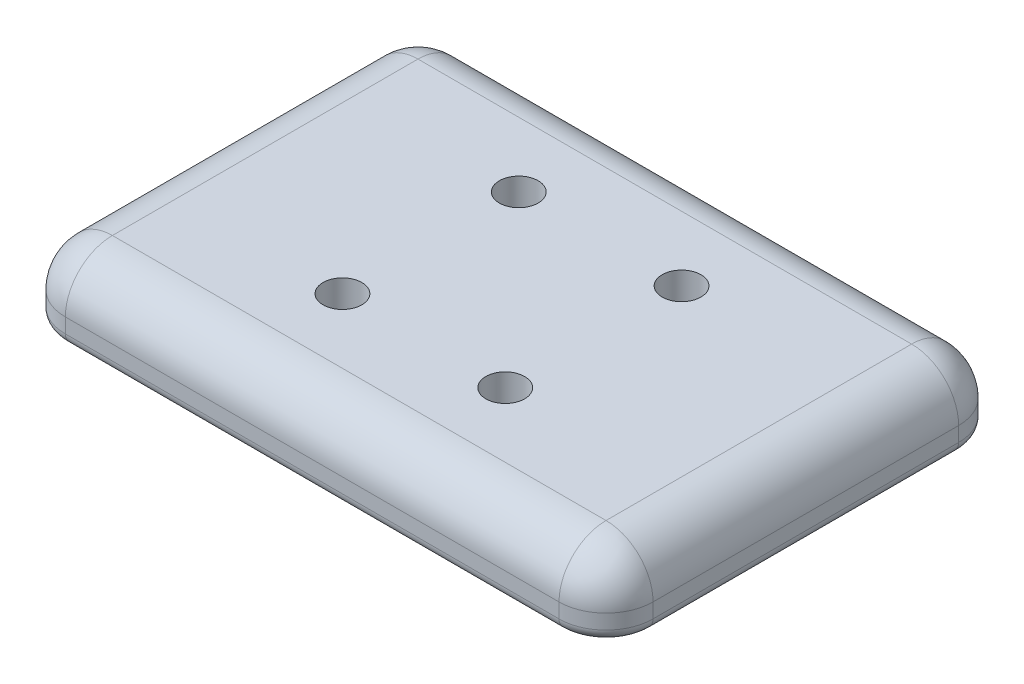
from build123d import *

# Parameters (mm, degrees)
SKETCH1_W                                    = 100
SKETCH1_H                                    = 68
BOSS_EXTRUDE1_DEPTH                          = 12.5
CBORE_FOR_M6_HEX_HEAD_CAP_SCREW1_D           = 6.6
CBORE_FOR_M6_HEX_HEAD_CAP_SCREW1_CBORE_D     = 14.547
CBORE_FOR_M6_HEX_HEAD_CAP_SCREW1_CBORE_DEPTH = 6
FILLET1_R                                    = 8
FILLET2_R                                    = 2


with BuildPart() as part:
    # Sketch1 → Boss-Extrude1 (new body)
    with BuildSketch(Plane(origin=(0, 0, 0), x_dir=(1, 0, 0), z_dir=(0, 1, 0))):
        with Locations((50, -34)):
            Rectangle(SKETCH1_W, SKETCH1_H)
    extrude(amount=BOSS_EXTRUDE1_DEPTH)

    # CBORE for M6 Hex Head Cap Screw1 (through all)
    with Locations(Plane(origin=(36.15, 0, 49), x_dir=(0, 0, -1), z_dir=(0, -1, 0))):
        with Locations((0, 0), (30, 0), (0, 27.7), (30, 27.7)):
            CounterBoreHole(CBORE_FOR_M6_HEX_HEAD_CAP_SCREW1_D / 2, CBORE_FOR_M6_HEX_HEAD_CAP_SCREW1_CBORE_D / 2, CBORE_FOR_M6_HEX_HEAD_CAP_SCREW1_CBORE_DEPTH)

    # Fillet1
    fillet1_edges = [part.edges().sort_by_distance(p)[0] for p in [
        (100, 12.5, 34),
        (50, 12.5, 0),
        (0, 12.5, 34),
        (50, 12.5, 68),
        (0, 6.25, 0),
        (100, 6.25, 0),
        (100, 6.25, 68),
        (0, 6.25, 68),
    ]]
    fillet(fillet1_edges, radius=FILLET1_R)

    # Fillet2
    fillet2_edges = [part.edges().sort_by_distance(p)[0] for p in [
        (100, 0, 34),
        (0, 0, 34),
        (50, 0, 0),
        (50, 0, 68),
        (97.656854249, 0, 2.343145751),
        (2.343145751, 0, 65.656854249),
        (2.343145751, 0, 2.343145751),
        (97.656854249, 0, 65.656854249),
    ]]
    fillet(fillet2_edges, radius=FILLET2_R)


solid = part.part
